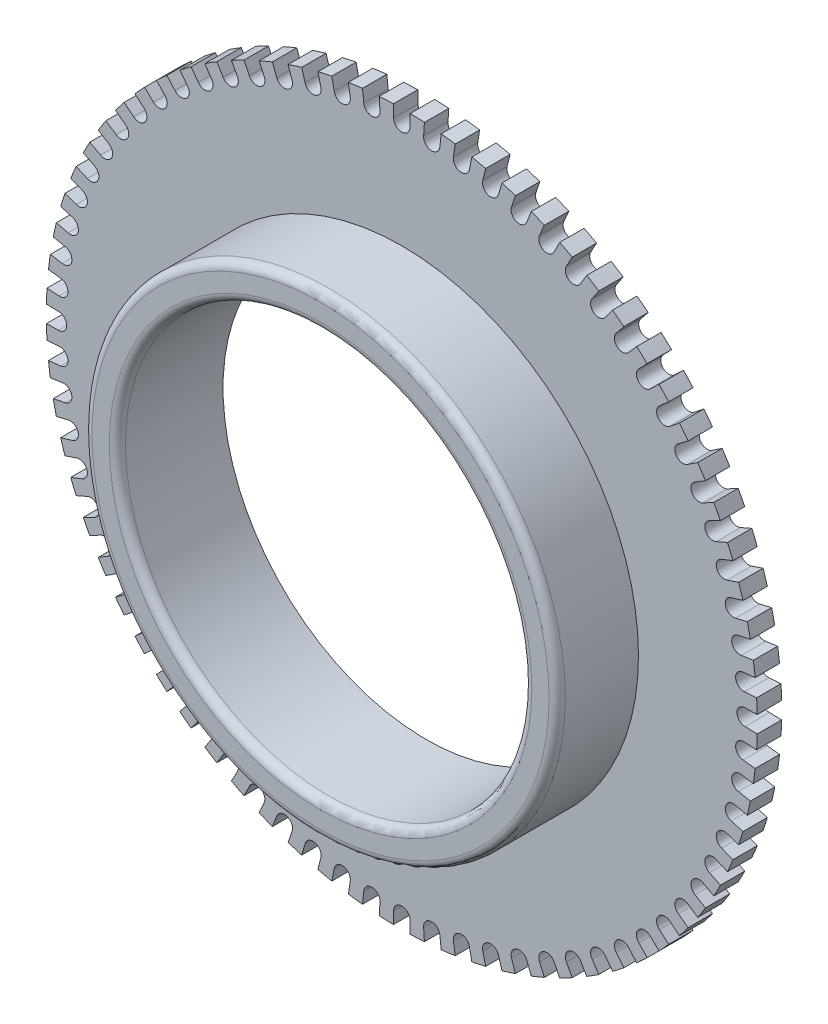
from build123d import *

# Parameters (mm, degrees)
SKETCH1_R           = 111.125
SKETCH1_R_2         = 63.5
BOSS_EXTRUDE1_DEPTH = 7.62
CUT_EXTRUDE1_DEPTH  = 8.62
CIRPATTERN1_COUNT   = 72
SKETCH3_R           = 73.969448616
SKETCH3_R_2         = 63.5
BOSS_EXTRUDE2_DEPTH = 25.4
FILLET1_R           = 2.54


with BuildPart() as part:
    # Sketch1 → Boss-Extrude1 (new body)
    with BuildSketch(Plane.XY):
        Circle(SKETCH1_R)
        Circle(SKETCH1_R_2, mode=Mode.SUBTRACT)
    extrude(amount=BOSS_EXTRUDE1_DEPTH)

    # Sketch2 → Cut-Extrude1 (cut, through all)
    with BuildSketch(Plane.XY.offset(7.62)):
        with BuildLine():
            Line((-2.54, 107.291775322), (-2.663785701, 112.520589327))
            Line((-2.663785701, 112.520589327), (2.663785701, 112.520589327))
            Line((2.663785701, 112.520589327), (2.54, 107.291775322))
            ThreePointArc((2.54, 107.291775322), (0, 104.751775322), (-2.54, 107.291775322))
        make_face()
    cut_extrude1 = extrude(amount=-CUT_EXTRUDE1_DEPTH, mode=Mode.SUBTRACT)

    # CirPattern1: Cut-Extrude1 ×72 about axis
    cirpattern1_axis = Axis((0, 0, 0), (0, 0, 1))
    for i in range(1, CIRPATTERN1_COUNT):
        add(cut_extrude1.rotate(cirpattern1_axis, i * 360 / CIRPATTERN1_COUNT), mode=Mode.SUBTRACT)

    # Sketch3 → Boss-Extrude2 (add)
    with BuildSketch(Plane.XY.offset(7.62)):
        Circle(SKETCH3_R)
        Circle(SKETCH3_R_2, mode=Mode.SUBTRACT)
    extrude(amount=BOSS_EXTRUDE2_DEPTH)

    # Fillet1
    fillet1_edges = [part.edges().sort_by_distance(p)[0] for p in [
        (-73.969448616, 0, 33.02),
        (-63.5, 0, 33.02),
    ]]
    fillet(fillet1_edges, radius=FILLET1_R)


solid = part.part
